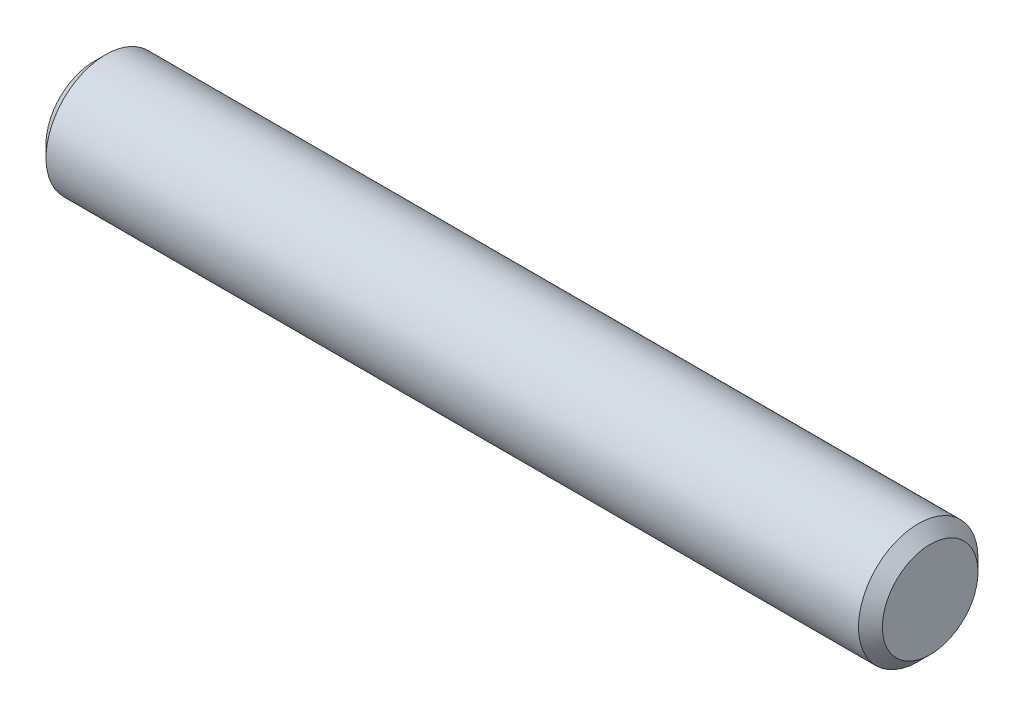
from build123d import *


with BuildPart() as part:
    # Sketch1 → Revolve1 (revolve)
    with BuildSketch(Plane.XY):
        Polygon((-22.225, 2.54), (-22.225, 0), (22.225, 0), (22.225, 2.54), (21.59, 3.175), (-21.59, 3.175), align=None)
    revolve(axis=Axis((-22.225, 0, 0), (1, 0, 0)))


solid = part.part
